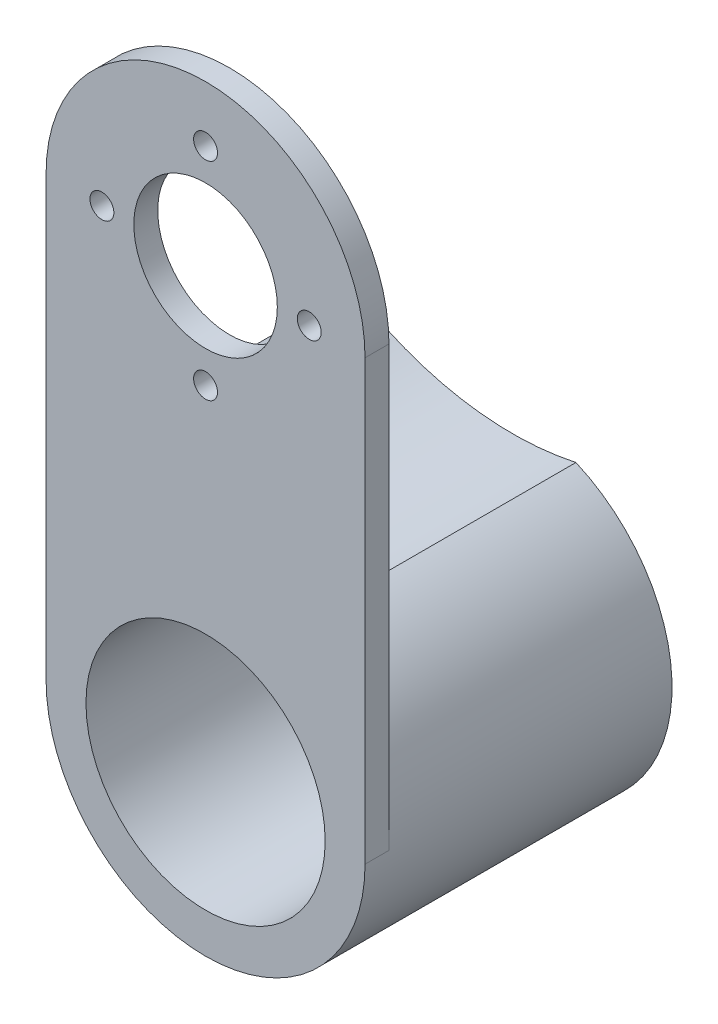
from build123d import *

# Parameters (mm, degrees)
ESQUISSE1_R      = 9
ESQUISSE1_R_2    = 15
ESQUISSE1_R_3    = 1.5
EXTRUSION1_DEPTH = 3
ESQUISSE2_R      = 9
EXTRUSION2_DEPTH = 38.5
ESQUISSE3_R      = 15
EXTRUSION3_DEPTH = 34.5


with BuildPart() as part:
    # Esquisse1 → Extrusion1 (new body)
    with BuildSketch(Plane.XY):
        with BuildLine():
            Line((0, 0), (0, 55))
            ThreePointArc((0, 55), (20, 75), (40, 55))
            Line((40, 55), (40, 0))
            ThreePointArc((40, 0), (20, -20), (0, 0))
        make_face()
        with Locations((20, 55)):
            Circle(ESQUISSE1_R, mode=Mode.SUBTRACT)
        with Locations((20, 0)):
            Circle(ESQUISSE1_R_2, mode=Mode.SUBTRACT)
        with Locations((20, 68)):
            Circle(ESQUISSE1_R_3, mode=Mode.SUBTRACT)
        with Locations((20, 42)):
            Circle(ESQUISSE1_R_3, mode=Mode.SUBTRACT)
        with Locations((7, 55)):
            Circle(ESQUISSE1_R_3, mode=Mode.SUBTRACT)
        with Locations((33, 55)):
            Circle(ESQUISSE1_R_3, mode=Mode.SUBTRACT)
    extrude(amount=EXTRUSION1_DEPTH)

    # Esquisse2 → Extrusion2 (add)
    with BuildSketch(Plane.XY.offset(3)):
        with BuildLine():
            Line((0, 0), (0, 23.278556149))
            ThreePointArc((0, 23.278556149), (13.490708127, 18.069265925), (27.949470784, 18.352272727))
            ThreePointArc((27.949470784, 18.352272727), (30.977490249, -16.718095222), (0, 0))
        make_face()
        with Locations((20, 0)):
            Circle(ESQUISSE2_R, mode=Mode.SUBTRACT)
    extrude(amount=-EXTRUSION2_DEPTH)

    # Esquisse3 → Extrusion3 (cut)
    with BuildSketch(Plane.XY.offset(3)):
        with Locations((20, 0)):
            Circle(ESQUISSE3_R)
    extrude(amount=-EXTRUSION3_DEPTH, mode=Mode.SUBTRACT)


solid = part.part
